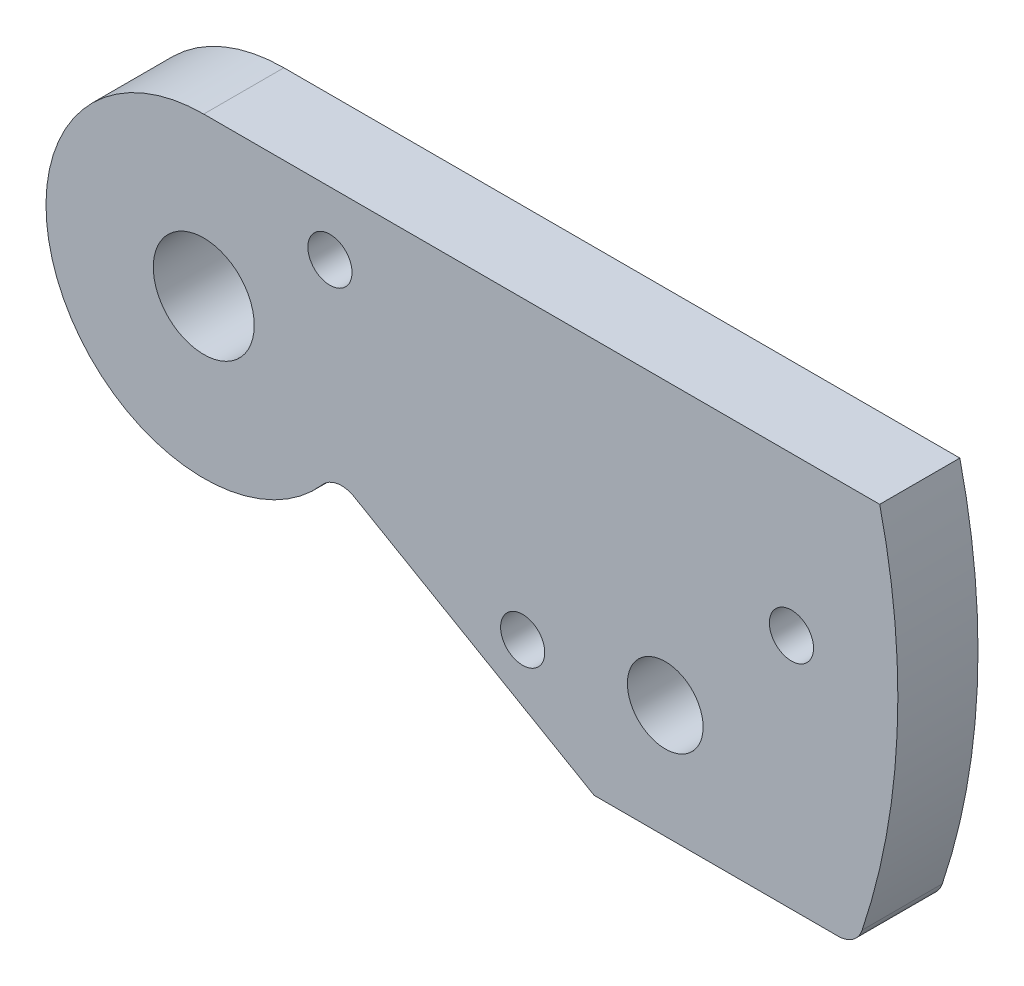
from build123d import *

# Parameters (mm, degrees)
SKETCH1_W           = 500
SKETCH1_H           = 150
SKETCH1_R           = 9.3
SKETCH1_R_2         = 3
SKETCH1_R_3         = 4
BOSS_EXTRUDE1_DEPTH = 6.35
CUT_EXTRUDE1_DEPTH  = 7
SKETCH4_R           = 9.3
CUT_EXTRUDE2_DEPTH  = 10
FILLET1_R           = 2
CUT_EXTRUDE4_DEPTH  = 10
SKETCH6_R           = 1.75
SKETCH6_R_2         = 3
CUT_EXTRUDE5_DEPTH  = 10


with BuildPart() as part:
    # Sketch1 → Boss-Extrude1 (new body)
    with BuildSketch(Plane.XY):
        with Locations((200, 0)):
            Rectangle(SKETCH1_W, SKETCH1_H)
        Circle(SKETCH1_R, mode=Mode.SUBTRACT)
        with BuildLine():
            ThreePointArc((303.793920425, 21.250000148), (340.59999997, 42.5), (377.406079545, 21.250000201))
            ThreePointArc((377.406079545, 21.250000201), (375.758965412, 15.102885723), (369.61185099, 16.750000063))
            ThreePointArc((369.61185099, 16.750000063), (340.600001147, 33.5), (311.588150157, 16.750002051))
            ThreePointArc((311.588150157, 16.750002051), (305.441035607, 15.102885134), (303.793920425, 21.250000148))
        make_face(mode=Mode.SUBTRACT)
        with Locations((377.1687, -9.7841)):
            Circle(SKETCH1_R_2, mode=Mode.SUBTRACT)
        with Locations((340.6, 0)):
            Circle(SKETCH1_R_3, mode=Mode.SUBTRACT)
    extrude(amount=BOSS_EXTRUDE1_DEPTH)

    # Sketch3 → Cut-Extrude1 (cut)
    with BuildSketch(Plane.XY.offset(6.35)):
        with BuildLine():
            Line((36.827355724, 55), (-50, 55))
            Line((-50, 55), (-50, -75))
            Line((-50, -75), (450, -75))
            Line((450, -75), (450, 55))
            Line((450, 55), (340.6, 55))
            ThreePointArc((340.6, 55), (379.490872965, 38.890872965), (395.6, 0))
            ThreePointArc((395.6, 0), (394.766919757, -9.536498518), (392.292916219, -18.7841))
            ThreePointArc((392.292916219, -18.7841), (329.589221669, -53.886573101), (285.681879129, 3))
            Line((285.681879129, 3), (30.896152423, 3))
            Line((30.896152423, 3), (21.172644276, 3))
            Line((21.172644276, 3), (9.086322138, -9.086322138))
            ThreePointArc((9.086322138, -9.086322138), (-9.086322138, -9.086322138), (-9.086322138, 9.086322138))
            Line((-9.086322138, 9.086322138), (36.827355724, 55))
        make_face()
        with BuildLine():
            Line((328.4653389, 3), (285.681879129, 3))
            ThreePointArc((285.681879129, 3), (329.589221669, -53.886573101), (392.292916219, -18.7841))
            Line((392.292916219, -18.7841), (371.532319214, -18.7841))
            Line((371.532319214, -18.7841), (351.002913897, -6.930323401))
            ThreePointArc((351.002913897, -6.930323401), (335.559903988, -11.438856245), (328.4653389, 3))
        make_face()
        Polygon((-50, 75), (-50, 55), (36.827355724, 55), (340.6, 55), (450, 55), (450, 75), align=None)
    extrude(amount=-CUT_EXTRUDE1_DEPTH, mode=Mode.SUBTRACT)

    # Sketch4 → Cut-Extrude2 (cut)
    with BuildSketch(Plane.XY.offset(6.35)):
        with BuildLine():
            Line((23.112698372, 8), (6.470027048, 24.642671324))
            Line((6.470027048, 24.642671324), (-9.086322138, 9.086322138))
            ThreePointArc((-9.086322138, 9.086322138), (4.917482106, 11.871851993), (12.85, 0))
            ThreePointArc((12.85, 0), (11.871851993, -4.917482106), (9.086322138, -9.086322138))
            Line((9.086322138, -9.086322138), (21.172644276, 3))
            Line((21.172644276, 3), (41, 3))
            Line((41, 3), (41, 8))
            Line((41, 8), (23.112698372, 8))
        make_face()
        with BuildLine():
            ThreePointArc((12.85, 0), (4.917482106, 11.871851993), (-9.086322138, 9.086322138))
            ThreePointArc((-9.086322138, 9.086322138), (-9.086322138, -9.086322138), (9.086322138, -9.086322138))
            ThreePointArc((9.086322138, -9.086322138), (11.871851993, -4.917482106), (12.85, 0))
        make_face()
        Circle(SKETCH4_R, mode=Mode.SUBTRACT)
        Polygon((36.827355724, 55), (30.827355724, 49), (50.827355724, 49), (50.827355724, 55), align=None)
    extrude(amount=-CUT_EXTRUDE2_DEPTH, mode=Mode.SUBTRACT)

    # Fillet1
    fillet1_edges = [part.edges().sort_by_distance(p)[0] for p in [
        (328.4653389, 3, 3.175),
        (351.002913897, -6.930323401, 3.175),
        (392.292916219, -18.7841, 3.175),
    ]]
    fillet(fillet1_edges, radius=FILLET1_R)

    # Sketch5 → Cut-Extrude4 (cut)
    with BuildSketch(Plane.XY.offset(6.35)):
        with BuildLine():
            ThreePointArc((328.129761947, 0.862068966), (332.07139701, 9.138540969), (340.6, 12.5))
            Line((340.6, 12.5), (394.160713214, 12.5))
            ThreePointArc((394.160713214, 12.5), (374.786985828, 43.084219849), (340.6, 55))
            Line((340.6, 55), (50.827355724, 55))
            Line((50.827355724, 55), (50.827355724, 49))
            Line((50.827355724, 49), (30.827355724, 49))
            Line((30.827355724, 49), (6.470027048, 24.642671324))
            Line((6.470027048, 24.642671324), (23.112698372, 8))
            Line((23.112698372, 8), (41, 8))
            Line((41, 8), (41, 3))
            Line((41, 3), (326.134523859, 3))
            ThreePointArc((326.134523859, 3), (327.596690413, 2.364576478), (328.129761947, 0.862068966))
        make_face()
        with BuildLine():
            ThreePointArc((311.588150157, 16.750002051), (305.441035607, 15.102885134), (303.793920425, 21.250000148))
            ThreePointArc((303.793920425, 21.250000148), (340.59999997, 42.5), (377.406079545, 21.250000201))
            ThreePointArc((377.406079545, 21.250000201), (375.758965412, 15.102885723), (369.61185099, 16.750000063))
            ThreePointArc((369.61185099, 16.750000063), (340.600001147, 33.5), (311.588150157, 16.750002051))
        make_face(mode=Mode.SUBTRACT)
    extrude(amount=-CUT_EXTRUDE4_DEPTH, mode=Mode.SUBTRACT)


with BuildPart() as cut_extrude4_kept_piece:
    # of the separate pieces the step leaves, the one the design keeps (cut_extrude4_pieces_kept)
    add(part.part.solids().sort_by_distance((340.6, 12.5, 0))[0])

    # Sketch6 → Cut-Extrude5 (cut)
    with BuildSketch(Plane.XY.offset(6.35)):
        with Locations((350.6, 7.5)):
            Circle(SKETCH6_R)
        with Locations((387.1687, 0)):
            Circle(SKETCH6_R)
        with Locations((377.1687, -9.7841)):
            Circle(SKETCH6_R_2)
        with Locations((365.870678247, -10.944141097)):
            Circle(SKETCH6_R)
    extrude(amount=-CUT_EXTRUDE5_DEPTH, mode=Mode.SUBTRACT)


solid = cut_extrude4_kept_piece.part
